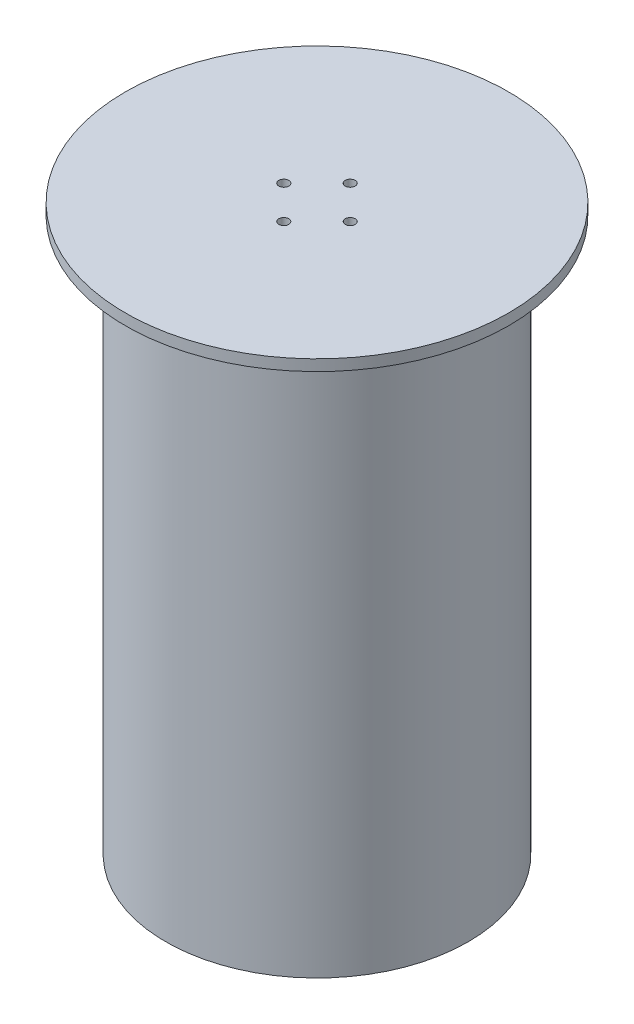
from build123d import *

# Parameters (mm, degrees)
CORTE_EXTRUS_O1_REACH = 512
ESBO_O2_R             = 4.5


with BuildPart() as part:
    # Esboço1 → Revolução1 (revolve)
    with BuildSketch(Plane.XY):
        Polygon((0, 510), (173, 510), (173, 500), (136.525, 500), (136.525, 0), (125.955, 0), (125.955, 10), (131.955, 10), (131.955, 500), (0, 500), align=None)
    revolve(axis=Axis((0, 0, 0), (0, 1, 0)))

    # Esboço2 → Corte-extrusão1 (cut, up to next)
    with BuildSketch(Plane(origin=(0, 510, 0), x_dir=(1, 0, 0), z_dir=(0, 1, 0)), mode=Mode.PRIVATE) as corte_extrus_o1_sk1:
        with Locations((0, 30)):
            Circle(ESBO_O2_R)
    corte_extrus_o1_tool1 = extrude(corte_extrus_o1_sk1.sketch, amount=-CORTE_EXTRUS_O1_REACH, mode=Mode.PRIVATE) & part.part
    add(corte_extrus_o1_tool1.solids().sort_by_distance((0, 510, -30))[0], mode=Mode.SUBTRACT)
    # Esboço2 → Corte-extrusão1 (cut, up to next)
    with BuildSketch(Plane(origin=(0, 510, 0), x_dir=(1, 0, 0), z_dir=(0, 1, 0)), mode=Mode.PRIVATE) as corte_extrus_o1_sk2:
        with Locations((30, 0)):
            Circle(ESBO_O2_R)
    corte_extrus_o1_tool2 = extrude(corte_extrus_o1_sk2.sketch, amount=-CORTE_EXTRUS_O1_REACH, mode=Mode.PRIVATE) & part.part
    add(corte_extrus_o1_tool2.solids().sort_by_distance((30, 510, 0))[0], mode=Mode.SUBTRACT)
    # Esboço2 → Corte-extrusão1 (cut, up to next)
    with BuildSketch(Plane(origin=(0, 510, 0), x_dir=(1, 0, 0), z_dir=(0, 1, 0)), mode=Mode.PRIVATE) as corte_extrus_o1_sk3:
        with Locations((0, -30)):
            Circle(ESBO_O2_R)
    corte_extrus_o1_tool3 = extrude(corte_extrus_o1_sk3.sketch, amount=-CORTE_EXTRUS_O1_REACH, mode=Mode.PRIVATE) & part.part
    add(corte_extrus_o1_tool3.solids().sort_by_distance((0, 510, 30))[0], mode=Mode.SUBTRACT)
    # Esboço2 → Corte-extrusão1 (cut, up to next)
    with BuildSketch(Plane(origin=(0, 510, 0), x_dir=(1, 0, 0), z_dir=(0, 1, 0)), mode=Mode.PRIVATE) as corte_extrus_o1_sk4:
        with Locations((-30, 0)):
            Circle(ESBO_O2_R)
    corte_extrus_o1_tool4 = extrude(corte_extrus_o1_sk4.sketch, amount=-CORTE_EXTRUS_O1_REACH, mode=Mode.PRIVATE) & part.part
    add(corte_extrus_o1_tool4.solids().sort_by_distance((-30, 510, 0))[0], mode=Mode.SUBTRACT)


solid = part.part
